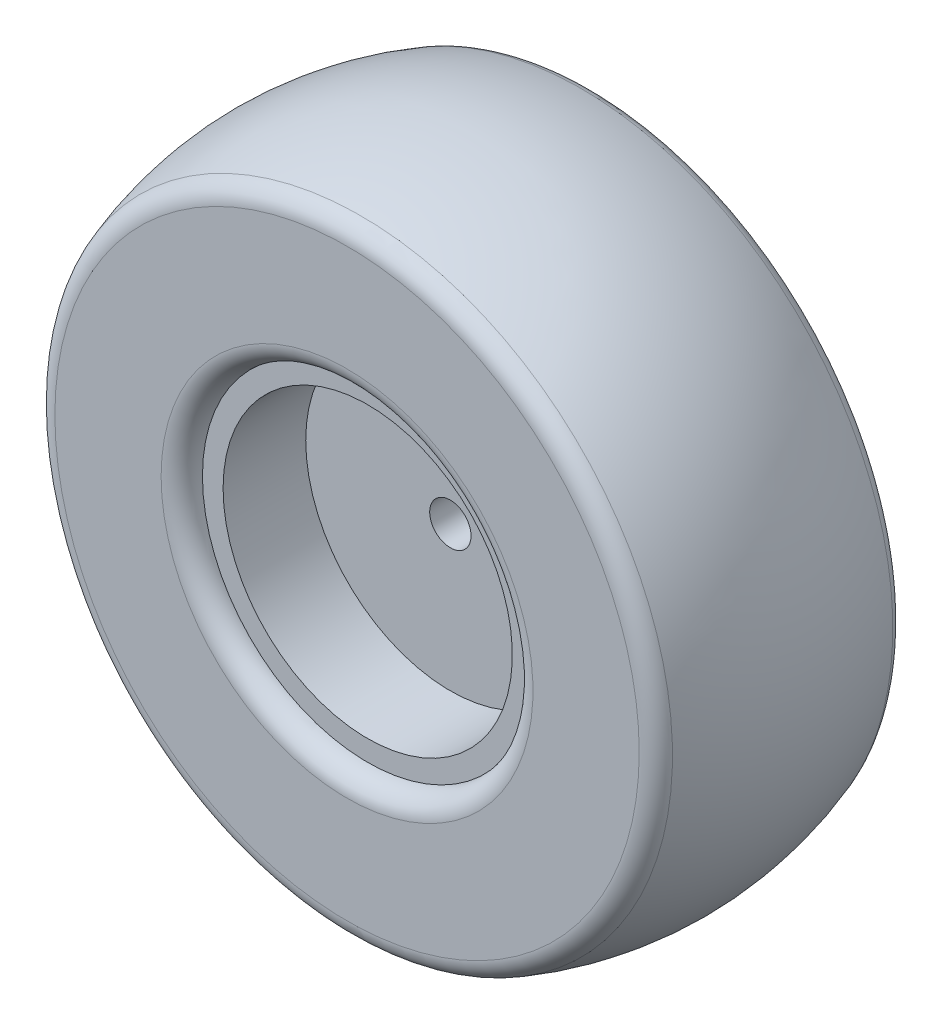
from build123d import *

# Parameters (mm, degrees)
SKETCH3_R               = 6.35
CUT_EXTRUDE1_DEPTH      = 32.75
CUT_EXTRUDE1_DEPTH_BACK = 45.45


with BuildPart() as part:
    # Sketch1 → Revolve1 (revolve)
    with BuildSketch(Plane(origin=(0, 0, 0), x_dir=(1, 0, 0), z_dir=(0, 1, 0))):
        with BuildLine():
            Line((-89.802561211, -38.1), (-57.15, -38.1))
            ThreePointArc((-57.15, -38.1), (-52.659871939, -36.240128061), (-50.8, -31.75))
            Line((-50.8, -31.75), (-50.8, 31.75))
            ThreePointArc((-50.8, 31.75), (-52.659871939, 36.240128061), (-57.15, 38.1))
            Line((-57.15, 38.1), (-89.802561211, 38.1))
            ThreePointArc((-89.802561211, 38.1), (-93.46873542, 36.934753289), (-95.789398625, 33.866666667))
            ThreePointArc((-95.789398625, 33.866666667), (-101.6, 0), (-95.789398625, -33.866666667))
            ThreePointArc((-95.789398625, -33.866666667), (-93.46873542, -36.934753289), (-89.802561211, -38.1))
        make_face()
    revolve(axis=Axis((0, 0, 0), (0, 0, 1)))

    # Sketch2 → Revolve2 (revolve)
    with BuildSketch(Plane(origin=(0, 0, 0), x_dir=(1, 0, 0), z_dir=(0, 1, 0))):
        Polygon((-44.45, 31.75), (-50.8, 31.75), (-50.8, -31.75), (-44.45, -31.75), (-44.45, -6.35), (0, -6.35), (0, 6.35), (-44.45, 6.35), align=None)
        with BuildLine():
            Line((-50.8, -31.75), (-50.8, 31.75))
            ThreePointArc((-50.8, 31.75), (-52.659871939, 36.240128061), (-57.15, 38.1))
            Line((-57.15, 38.1), (-89.802561211, 38.1))
            ThreePointArc((-89.802561211, 38.1), (-93.46873542, 36.934753289), (-95.789398625, 33.866666667))
            ThreePointArc((-95.789398625, 33.866666667), (-101.6, 0), (-95.789398625, -33.866666667))
            ThreePointArc((-95.789398625, -33.866666667), (-93.46873542, -36.934753289), (-89.802561211, -38.1))
            Line((-89.802561211, -38.1), (-57.15, -38.1))
            ThreePointArc((-57.15, -38.1), (-52.659871939, -36.240128061), (-50.8, -31.75))
        make_face()
    revolve(axis=Axis((0, 0, 0), (0, 0, 1)))

    # Sketch3 → Cut-Extrude1 (cut, two sides)
    with BuildSketch(Plane.XY.offset(6.35)) as cut_extrude1_sk:
        Circle(SKETCH3_R)
    extrude(amount=CUT_EXTRUDE1_DEPTH, mode=Mode.SUBTRACT)
    extrude(cut_extrude1_sk.sketch, amount=-CUT_EXTRUDE1_DEPTH_BACK, mode=Mode.SUBTRACT)


solid = part.part
